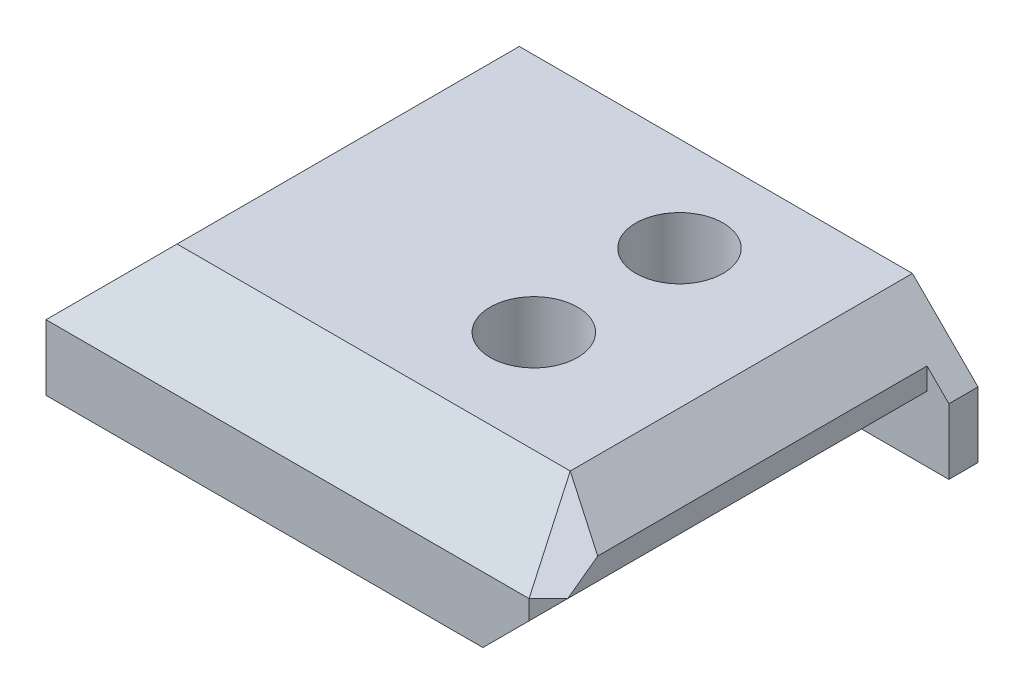
from build123d import *

# Parameters (mm, degrees)
SKETCH1_W               = 36
SKETCH1_H               = 9
BOSS_EXTRUDE1_DEPTH     = 28
CUT_EXTRUDE1_DEPTH      = 28
CUT_EXTRUDE2_DEPTH      = 36
SKETCH5_W               = 11.440376565
SKETCH5_H               = 15.618965423
CUT_EXTRUDE4_DEPTH      = 2
CUT_EXTRUDE5_DEPTH      = 2
CUT_EXTRUDE5_DEPTH_BACK = 2
CUT_EXTRUDE6_DEPTH      = 26
CUT_EXTRUDE7_DEPTH      = 26
SKETCH10_R              = 3
CUT_EXTRUDE8_DEPTH      = 7
SKETCH11_R              = 1.5
CUT_EXTRUDE9_DEPTH      = 2
SKETCH12_R              = 1.5
CUT_EXTRUDE10_DEPTH     = 9
SKETCH13_R              = 3
CUT_EXTRUDE11_DEPTH     = 7


with BuildPart() as part:
    # Sketch1 → Boss-Extrude1 (new body)
    with BuildSketch(Plane.XY):
        with Locations((18, 4.5)):
            Rectangle(SKETCH1_W, SKETCH1_H)
    extrude(amount=BOSS_EXTRUDE1_DEPTH)

    # Sketch2 → Cut-Extrude1 (cut)
    with BuildSketch(Plane.XY):
        Polygon((0, 4.5), (4.5, 9), (0, 9), align=None)
        Polygon((36, 4.5), (31.5, 9), (36, 9), align=None)
    extrude(amount=CUT_EXTRUDE1_DEPTH, mode=Mode.SUBTRACT)

    # Sketch3 → Cut-Extrude2 (cut)
    with BuildSketch(Plane(origin=(0, 0, 0), x_dir=(0, 0, -1), z_dir=(1, 0, 0))):
        Polygon((-28, 4.5), (-23.5, 9), (-28, 9), align=None)
    extrude(amount=CUT_EXTRUDE2_DEPTH, mode=Mode.SUBTRACT)

    # Sketch5 → Cut-Extrude4 (cut)
    with BuildSketch(Plane(origin=(32, 0, 32), x_dir=(0, 1, 0), z_dir=(0.707106781, 0, 0.707106781))):
        with Locations((5.720188283, -5.935696583)):
            Rectangle(SKETCH5_W, SKETCH5_H)
    extrude(amount=-CUT_EXTRUDE4_DEPTH, mode=Mode.SUBTRACT)

    # Sketch6 → Cut-Extrude5 (cut, two sides)
    with BuildSketch(Plane(origin=(4, 0, -4), x_dir=(0.577350269, -0.577350269, 0.577350269), z_dir=(-0.707106781, 0, 0.707106781))) as cut_extrude5_sk:
        Polygon((26.558112383, 29.802125204), (32.719347855, 28.647424665), (30.19862658, 32.212262879), align=None)
    extrude(amount=CUT_EXTRUDE5_DEPTH, mode=Mode.SUBTRACT)
    extrude(cut_extrude5_sk.sketch, amount=-CUT_EXTRUDE5_DEPTH_BACK, mode=Mode.SUBTRACT)

    # Sketch7 → Cut-Extrude6 (cut)
    with BuildSketch(Plane.XY):
        Polygon((5, 0), (5, 3), (5.707106781, 3.707106781), (13.104524105, 3.707106781), (13.811630886, 3), (13.811630886, 0), align=None)
    extrude(amount=CUT_EXTRUDE6_DEPTH, mode=Mode.SUBTRACT)

    # Sketch8 → Cut-Extrude7 (cut)
    with BuildSketch(Plane.XY.offset(28)):
        Polygon((36, 0), (30, 0), (34.5, 4.5), (34.5, 6), (36, 6), align=None)
    extrude(amount=-CUT_EXTRUDE7_DEPTH, mode=Mode.SUBTRACT)

    # Sketch10 → Cut-Extrude8 (cut)
    with BuildSketch(Plane(origin=(0, 9, 0), x_dir=(1, 0, 0), z_dir=(0, 1, 0))):
        with Locations((22, -6.5)):
            Circle(SKETCH10_R)
    extrude(amount=-CUT_EXTRUDE8_DEPTH, mode=Mode.SUBTRACT)

    # Sketch11 → Cut-Extrude9 (cut)
    with BuildSketch(Plane(origin=(0, 2, 0), x_dir=(1, 0, 0), z_dir=(0, 1, 0))):
        with Locations((22, -6.5)):
            Circle(SKETCH11_R)
    extrude(amount=-CUT_EXTRUDE9_DEPTH, mode=Mode.SUBTRACT)

    # Sketch12 → Cut-Extrude10 (cut)
    with BuildSketch(Plane(origin=(0, 0, 0), x_dir=(1, 0, 0), z_dir=(0, 1, 0))):
        with Locations((22, -16.5)):
            Circle(SKETCH12_R)
    extrude(amount=CUT_EXTRUDE10_DEPTH, mode=Mode.SUBTRACT)

    # Sketch13 → Cut-Extrude11 (cut)
    with BuildSketch(Plane(origin=(0, 9, 0), x_dir=(1, 0, 0), z_dir=(0, 1, 0))):
        with Locations((22, -16.5)):
            Circle(SKETCH13_R)
    extrude(amount=-CUT_EXTRUDE11_DEPTH, mode=Mode.SUBTRACT)


solid = part.part
